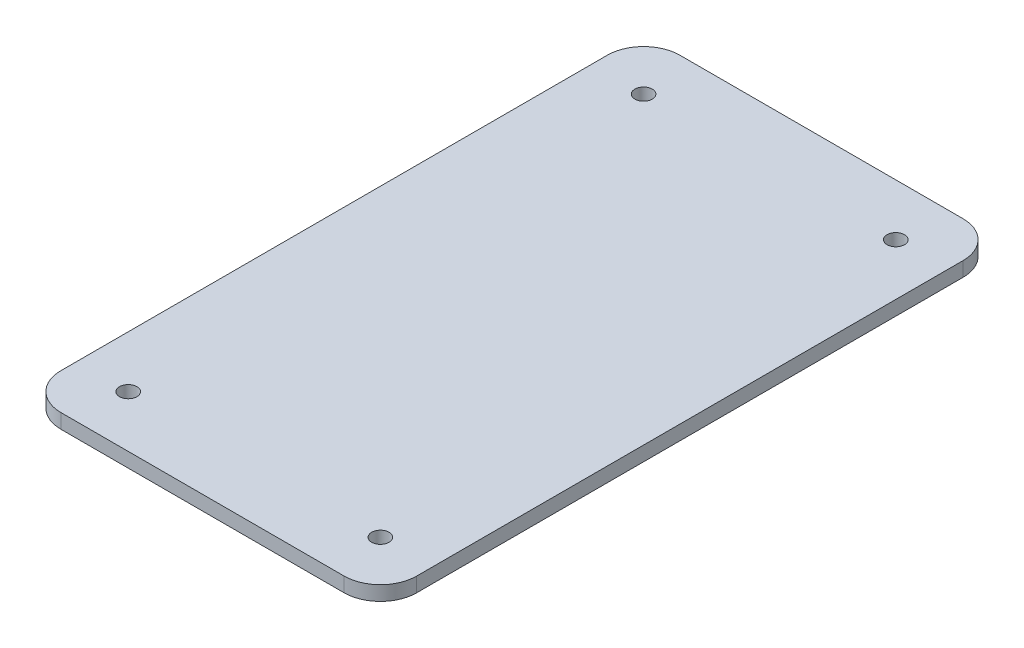
from build123d import *

# Parameters (mm, degrees)
SKETCH1_W             = 49.784
SKETCH1_H             = 86.614
BOSS_EXTRUDE1_DEPTH   = 2.032
FILLET1_R             = 5.08
F_2_CLEARANCE_HOLE1_D = 2.4384


with BuildPart() as part:
    # Sketch1 → Boss-Extrude1 (new body)
    with BuildSketch(Plane(origin=(0, 0, 0), x_dir=(1, 0, 0), z_dir=(0, 1, 0))):
        Rectangle(SKETCH1_W, SKETCH1_H)
    extrude(amount=BOSS_EXTRUDE1_DEPTH)

    # Fillet1
    fillet1_edges = [part.edges().sort_by_distance(p)[0] for p in [
        (-24.892, 1.016, -43.307),
        (24.892, 1.016, -43.307),
        (24.892, 1.016, 43.307),
        (-24.892, 1.016, 43.307),
    ]]
    fillet(fillet1_edges, radius=FILLET1_R)

    # #2 Clearance Hole1 (through all)
    with Locations(Plane(origin=(0, 0, 0), x_dir=(-1, 0, 0), z_dir=(0, -1, 0))):
        with Locations((-17.653, 36.051955783), (17.636955783, 36.051955783), (-17.653, -36.068), (17.636955783, -36.068)):
            Hole(F_2_CLEARANCE_HOLE1_D / 2)


solid = part.part
